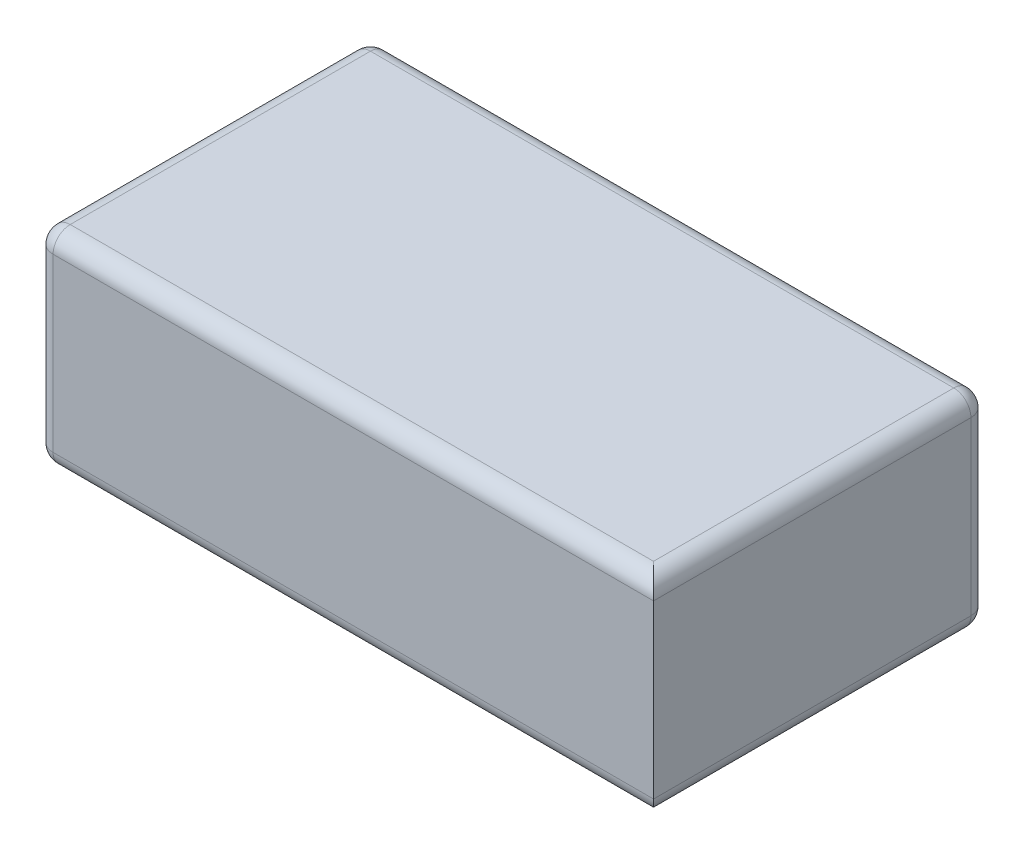
from build123d import *

# Parameters (mm, degrees)
ESQUISSE1_W      = 72
ESQUISSE1_H      = 39
EXTRUSION2_DEPTH = 24
CONG_3_R         = 2


with BuildPart() as part:
    # Esquisse1 → Extrusion2 (new body)
    with BuildSketch(Plane(origin=(0, 0, 0), x_dir=(1, 0, 0), z_dir=(0, 1, 0))):
        with Locations((36, 19.5)):
            Rectangle(ESQUISSE1_W, ESQUISSE1_H)
    extrude(amount=EXTRUSION2_DEPTH)

    # Congé3
    cong_3_edges = [part.edges().sort_by_distance(p)[0] for p in [
        (72, 24, -19.5),
        (36, 24, -39),
        (0, 24, -19.5),
        (36, 0, -39),
        (72, 0, -19.5),
        (36, 0, 0),
        (0, 0, -19.5),
        (36, 24, 0),
        (0, 12, -39),
        (72, 12, -39),
        (0, 12, 0),
    ]]
    fillet(cong_3_edges, radius=CONG_3_R)


solid = part.part
